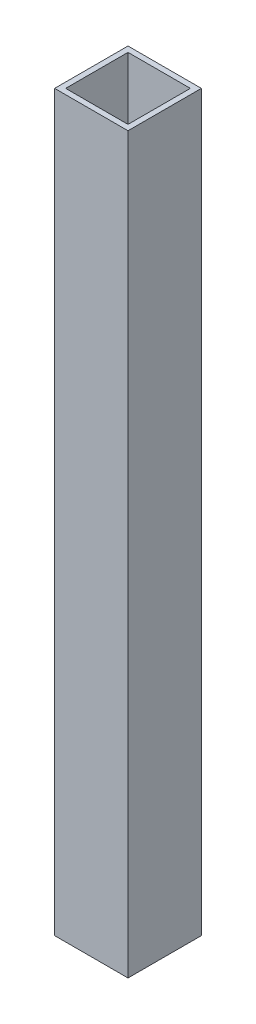
from build123d import *

# Parameters (mm, degrees)
SKETCH2_W           = 40
SKETCH2_H           = 40
BOSS_EXTRUDE2_DEPTH = 400
SKETCH3_W           = 34
SKETCH3_H           = 34
CUT_EXTRUDE1_DEPTH  = 401


with BuildPart() as part:
    # Sketch2 → Boss-Extrude2 (new body)
    with BuildSketch(Plane(origin=(0, 0, 0), x_dir=(1, 0, 0), z_dir=(0, 1, 0))):
        Rectangle(SKETCH2_W, SKETCH2_H)
    extrude(amount=BOSS_EXTRUDE2_DEPTH)

    # Sketch3 → Cut-Extrude1 (cut, through all)
    with BuildSketch(Plane(origin=(0, 400, 0), x_dir=(1, 0, 0), z_dir=(0, 1, 0))):
        Rectangle(SKETCH3_W, SKETCH3_H)
    extrude(amount=-CUT_EXTRUDE1_DEPTH, mode=Mode.SUBTRACT)


solid = part.part
